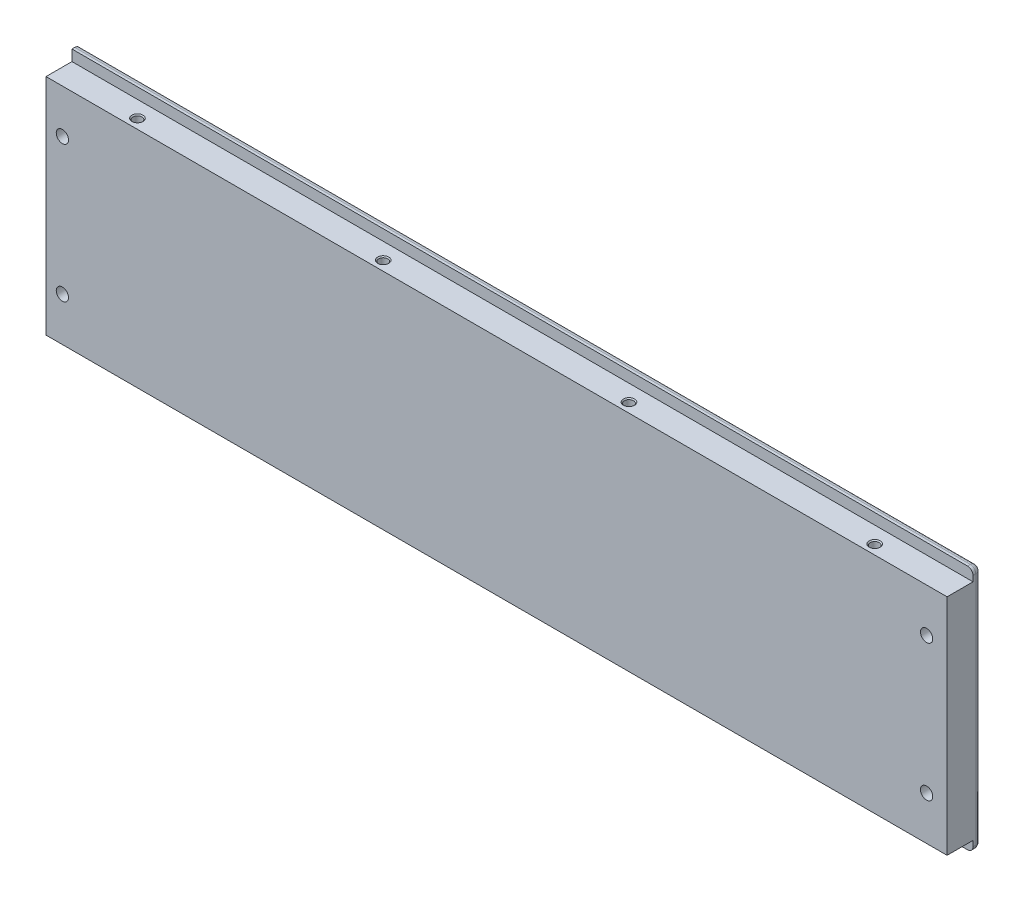
from build123d import *

# Parameters (mm, degrees)
SKETCH_1_W                     = 330
SKETCH_1_H                     = 90
EXTRUDE_1_DEPTH                = 12.5
SKETCH_2_W                     = 9.5
SKETCH_2_H                     = 4
CUT_EXTRUDE_1_DEPTH            = 331
HOLE_WIZARD_M4_1_D             = 4.5
HOLE_WIZARD_M4_1_CSINK_D       = 8.96
HOLE_WIZARD_M4_1_CSINK_ANGLE   = 90
HOLE_WIZARD_M4_1_2_D           = 3.3
HOLE_WIZARD_M4_1_2_CSINK_D     = 4.05
HOLE_WIZARD_M4_1_2_CSINK_ANGLE = 90
FILLET_2_R                     = 2
FILLET_3_R                     = 2


with BuildPart() as part:
    # 草圖1 → 填料-伸長1 (new body)
    with BuildSketch(Plane.XY):
        with Locations((165, 45)):
            Rectangle(SKETCH_1_W, SKETCH_1_H)
    extrude(amount=EXTRUDE_1_DEPTH)

    # 草圖2 → 除料-伸長1 (cut, through all)
    with BuildSketch(Plane.ZY):
        with Locations((7.75, 88)):
            Rectangle(SKETCH_2_W, SKETCH_2_H)
        with Locations((7.75, 2)):
            Rectangle(SKETCH_2_W, SKETCH_2_H)
    extrude(amount=-CUT_EXTRUDE_1_DEPTH, mode=Mode.SUBTRACT)

    # Hole Wizard M4 _1 (through all)
    with Locations(Plane(origin=(0, 0, 0), x_dir=(-1, 0, 0), z_dir=(0, 0, -1))):
        with Locations((-322.5, 70), (-322.5, 20), (-6, 70), (-6, 20)):
            CounterSinkHole(HOLE_WIZARD_M4_1_D / 2, HOLE_WIZARD_M4_1_CSINK_D / 2, counter_sink_angle=HOLE_WIZARD_M4_1_CSINK_ANGLE)

    # Hole Wizard M4 _1 2 (through all)
    with Locations(Plane(origin=(0, 86, 0), x_dir=(1, 0, 0), z_dir=(0, 1, 0))):
        with Locations((30, -9), (120, -9), (210, -9), (300, -9)):
            CounterSinkHole(HOLE_WIZARD_M4_1_2_D / 2, HOLE_WIZARD_M4_1_2_CSINK_D / 2, counter_sink_angle=HOLE_WIZARD_M4_1_2_CSINK_ANGLE)

    # 圓角2
    fillet_2_edges = [part.edges().sort_by_distance(p)[0] for p in [
        (330, 90, 1.5),
        (330, 0, 1.5),
    ]]
    fillet(fillet_2_edges, radius=FILLET_2_R)

    # 圓角3
    fillet_3_edges = [part.edges().sort_by_distance(p)[0] for p in [
        (164, 90, 0),
        (164, 0, 0),
        (330, 45, 0),
    ]]
    fillet(fillet_3_edges, radius=FILLET_3_R)


solid = part.part
